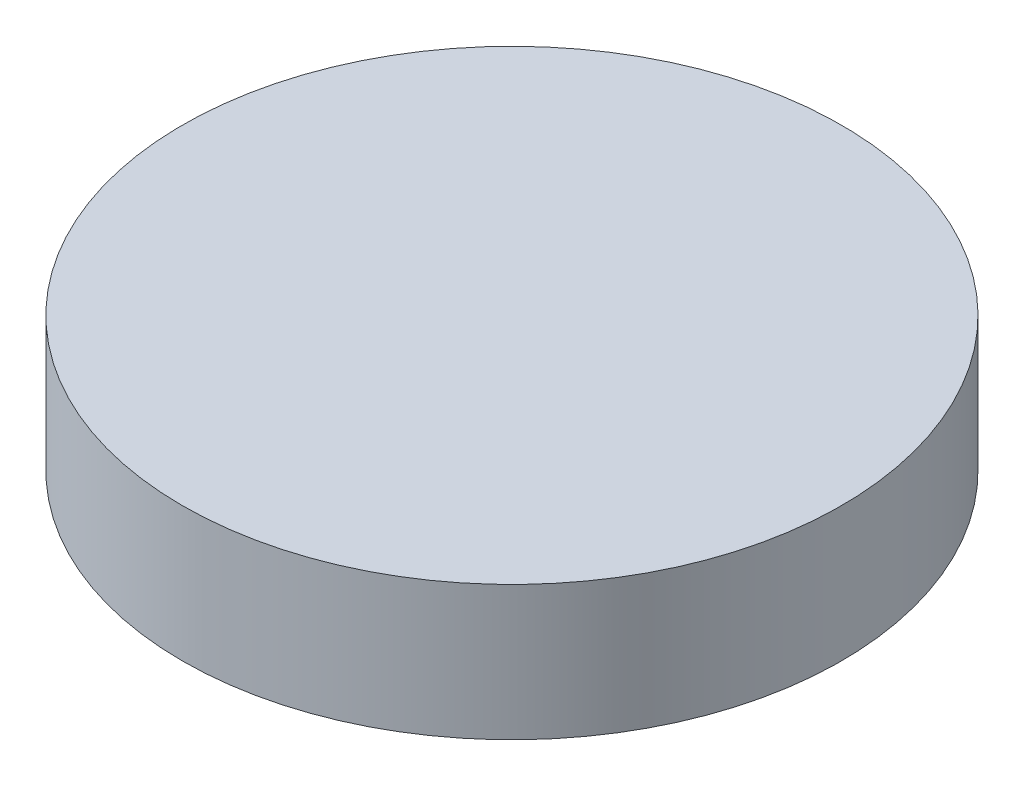
from build123d import *

# Parameters (mm, degrees)
IZIM1_R                     = 12.25
Y_KSEKLIK_EKSTR_ZYON1_DEPTH = 5


with BuildPart() as part:
    # Çizim1 → Yükseklik-Ekstrüzyon1 (new body)
    with BuildSketch(Plane(origin=(0, 0, 0), x_dir=(1, 0, 0), z_dir=(0, 1, 0))):
        with Locations((-10.592335453, -2.180448822)):
            Circle(IZIM1_R)
    extrude(amount=Y_KSEKLIK_EKSTR_ZYON1_DEPTH)


solid = part.part
